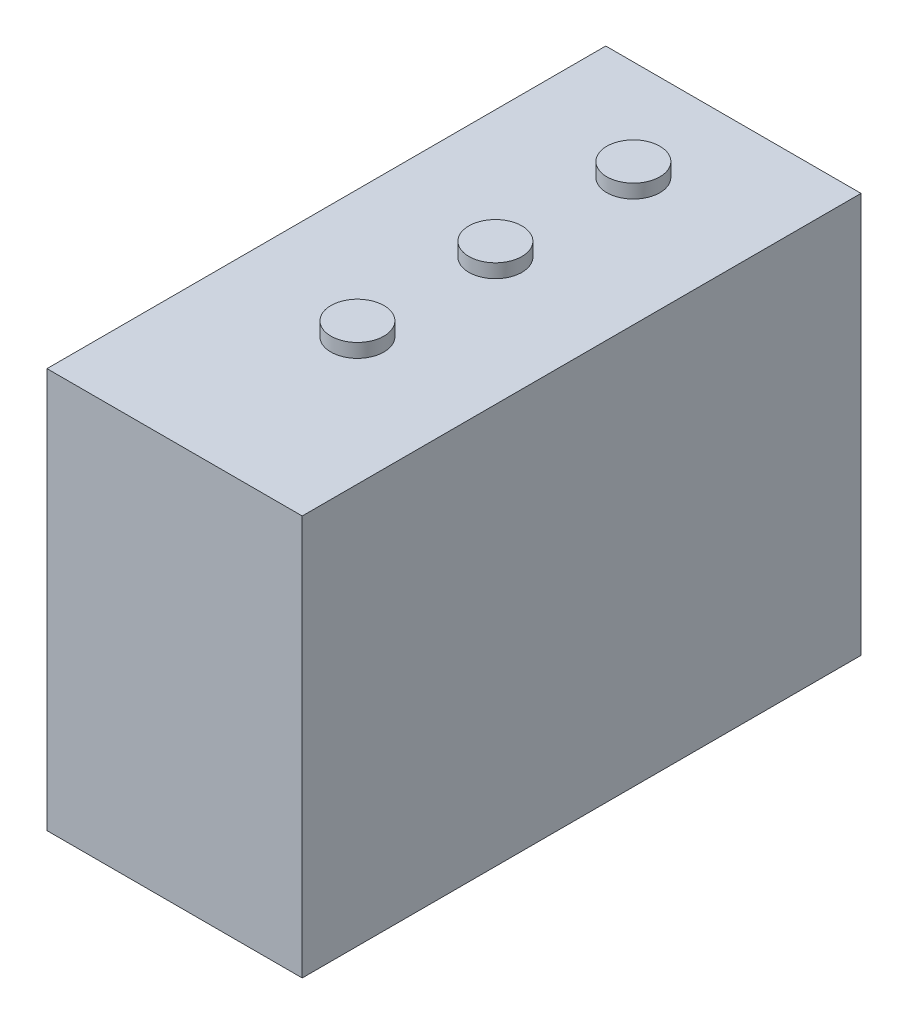
from build123d import *

# Parameters (mm, degrees)
SKETCH_1_W      = 37
SKETCH_1_H      = 58
EXTRUDE_1_DEPTH = 81
SKETCH_3_R      = 3.842727579
EXTRUDE_2_DEPTH = 2


with BuildPart() as part:
    # 草图1 → 凸台-拉伸1 (new body)
    with BuildSketch(Plane.XY):
        Rectangle(SKETCH_1_W, SKETCH_1_H)
    extrude(amount=EXTRUDE_1_DEPTH)

    # 草图3 → 凸台-拉伸2 (add)
    with BuildSketch(Plane(origin=(0, 29, 0), x_dir=(1, 0, 0), z_dir=(0, 1, 0))):
        with Locations((0, -14.500282865)):
            Circle(SKETCH_3_R)
        with Locations((0, -34.500282865)):
            Circle(SKETCH_3_R)
        with Locations((0, -54.500282865)):
            Circle(SKETCH_3_R)
    extrude(amount=EXTRUDE_2_DEPTH)


solid = part.part
